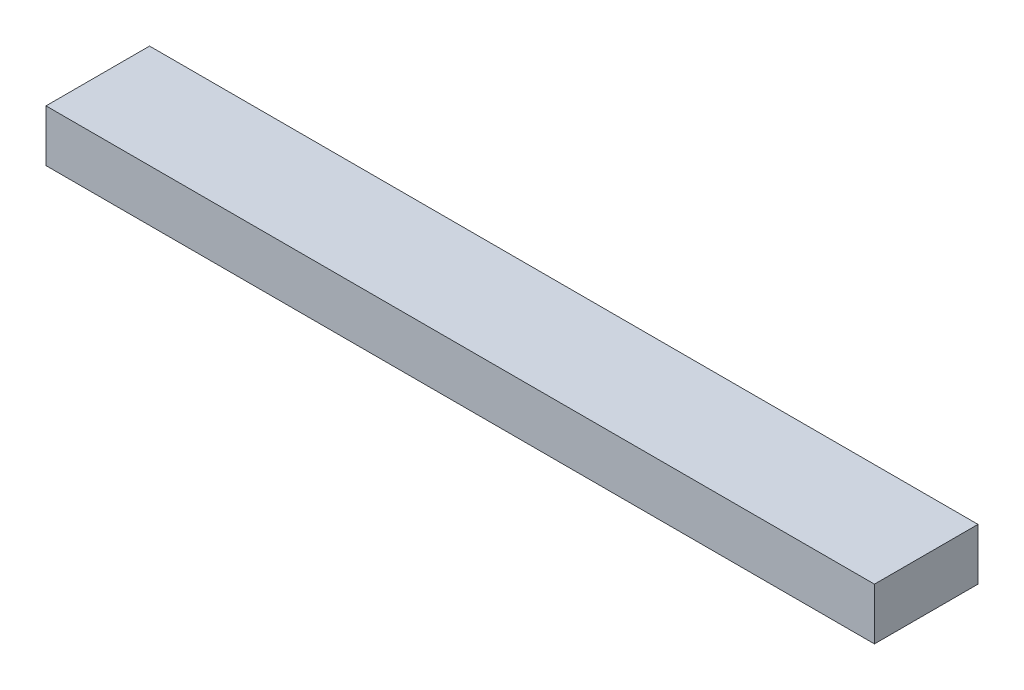
from build123d import *

# Parameters (mm, degrees)
SKETCH1_W           = 38.1
SKETCH1_H           = 19.05
BOSS_EXTRUDE1_DEPTH = 304.8


with BuildPart() as part:
    # Sketch1 → Boss-Extrude1 (new body)
    with BuildSketch(Plane(origin=(0, 0, 0), x_dir=(0, 0, -1), z_dir=(1, 0, 0))):
        with Locations((19.05, 9.525)):
            Rectangle(SKETCH1_W, SKETCH1_H)
    extrude(amount=BOSS_EXTRUDE1_DEPTH)


solid = part.part
